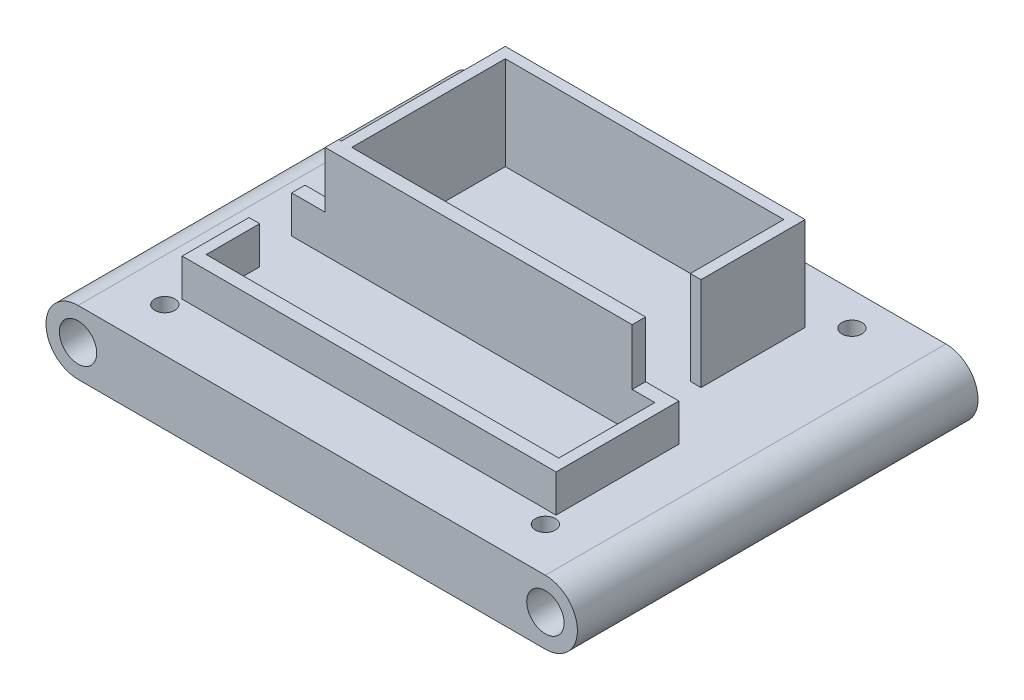
from build123d import *

# Parameters (mm, degrees)
SKETCH1_R           = 3.556
BOSS_EXTRUDE1_DEPTH = 76.2
SKETCH2_R           = 1.905
CUT_EXTRUDE1_DEPTH  = 6.604
BOSS_EXTRUDE2_DEPTH = 17.78
SKETCH4_W           = 6.858
SKETCH4_H           = 2.54
SKETCH4_W_2         = 2.54
SKETCH4_H_2         = 10.16
SKETCH4_H_3         = 18.288
BOSS_EXTRUDE3_DEPTH = 7.112
SKETCH5_R           = 1.905
CUT_EXTRUDE3_DEPTH  = 7.112
SKETCH6_R           = 1.905
CUT_EXTRUDE4_DEPTH  = 7.112
SKETCH8_W           = 0.508
SKETCH8_H           = 20.32
CUT_EXTRUDE5_DEPTH  = 17.78
SKETCH9_W           = 0.508
SKETCH9_H           = 2.54
CUT_EXTRUDE6_DEPTH  = 7.112
SKETCH10_W          = 0.508
SKETCH10_H          = 12.7
SKETCH10_H_2        = 23.368
CUT_EXTRUDE7_DEPTH  = 7.112
SKETCH11_W          = 57.041716114
SKETCH11_H          = 0.508
CUT_EXTRUDE8_DEPTH  = 17.78


with BuildPart() as part:
    # Sketch1 → Boss-Extrude1 (new body)
    with BuildSketch(Plane.XY):
        with BuildLine():
            Line((-44.45, 6.096), (44.45, 6.096))
            ThreePointArc((44.45, 6.096), (50.546, 0), (44.45, -6.096))
            Line((44.45, -6.096), (-44.45, -6.096))
            ThreePointArc((-44.45, -6.096), (-50.546, 0), (-44.45, 6.096))
        make_face()
        with Locations((-44.45, 0)):
            Circle(SKETCH1_R, mode=Mode.SUBTRACT)
        with Locations((44.45, 0)):
            Circle(SKETCH1_R, mode=Mode.SUBTRACT)
    extrude(amount=BOSS_EXTRUDE1_DEPTH)

    # Sketch2 → Cut-Extrude1 (cut)
    with BuildSketch(Plane.XZ.offset(6.096)):
        with Locations((-9.144, 69.215)):
            Circle(SKETCH2_R)
        with Locations((27.051, 60.833)):
            Circle(SKETCH2_R)
        with Locations((-28.956, 69.215)):
            Circle(SKETCH2_R)
        with Locations((-28.956, 6.985)):
            Circle(SKETCH2_R)
        with Locations((-9.144, 6.985)):
            Circle(SKETCH2_R)
        with Locations((11.049, 60.833)):
            Circle(SKETCH2_R)
        with Locations((11.049, 15.367)):
            Circle(SKETCH2_R)
        with Locations((27.051, 15.367)):
            Circle(SKETCH2_R)
    extrude(amount=-CUT_EXTRUDE1_DEPTH, mode=Mode.SUBTRACT)

    # Sketch3 → Boss-Extrude2 (add)
    with BuildSketch(Plane(origin=(0, 6.096, 0), x_dir=(1, 0, 0), z_dir=(0, 1, 0))):
        Polygon((-29.21, -10.16), (-29.21, -44.45), (29.21, -44.45), (29.21, -41.91), (-26.67, -41.91), (-26.67, -12.7), (26.307716114, -12.7), (26.307716114, -30.48), (28.847716114, -30.48), (28.847716114, -10.16), align=None)
    extrude(amount=BOSS_EXTRUDE2_DEPTH)

    # Sketch4 → Boss-Extrude3 (add)
    with BuildSketch(Plane(origin=(0, 6.096, 0), x_dir=(1, 0, 0), z_dir=(0, 1, 0))):
        with Locations((-32.639, -43.18)):
            Rectangle(SKETCH4_W, SKETCH4_H)
        with Locations((-34.798, -57.658)):
            Rectangle(SKETCH4_W_2, SKETCH4_H_2)
        Polygon((36.068, -62.738), (33.528, -62.738), (-33.528, -62.738), (-36.068, -62.738), (-36.068, -65.278), (36.068, -65.278), align=None)
        with Locations((34.798, -53.594)):
            Rectangle(SKETCH4_W_2, SKETCH4_H_3)
        with Locations((32.639, -43.18)):
            Rectangle(SKETCH4_W, SKETCH4_H)
    extrude(amount=BOSS_EXTRUDE3_DEPTH)

    # Sketch5 → Cut-Extrude3 (cut)
    with BuildSketch(Plane(origin=(0, 6.096, 0), x_dir=(1, 0, 0), z_dir=(0, 1, 0))):
        with Locations((36.068, -67.818)):
            Circle(SKETCH5_R)
        with Locations((32.911716114, -6.35)):
            Circle(SKETCH5_R)
    extrude(amount=-CUT_EXTRUDE3_DEPTH, mode=Mode.SUBTRACT)

    # Sketch6 → Cut-Extrude4 (cut)
    with BuildSketch(Plane(origin=(0, 6.096, 0), x_dir=(1, 0, 0), z_dir=(0, 1, 0))):
        with Locations((-33.274, -6.35)):
            Circle(SKETCH6_R)
        with Locations((-36.322, -67.818)):
            Circle(SKETCH6_R)
    extrude(amount=-CUT_EXTRUDE4_DEPTH, mode=Mode.SUBTRACT)

    # Sketch8 → Cut-Extrude5 (cut)
    with BuildSketch(Plane(origin=(0, 23.876, 0), x_dir=(1, 0, 0), z_dir=(0, 1, 0))):
        with Locations((28.593716114, -20.32)):
            Rectangle(SKETCH8_W, SKETCH8_H)
        Polygon((-28.702, -41.91), (-28.702, -10.16), (-29.21, -10.16), (-29.21, -41.825929555), align=None)
    extrude(amount=-CUT_EXTRUDE5_DEPTH, mode=Mode.SUBTRACT)

    # Sketch9 → Cut-Extrude6 (cut)
    with BuildSketch(Plane(origin=(0, 13.208, 0), x_dir=(1, 0, 0), z_dir=(0, 1, 0))):
        with Locations((-35.814, -43.18)):
            Rectangle(SKETCH9_W, SKETCH9_H)
    extrude(amount=-CUT_EXTRUDE6_DEPTH, mode=Mode.SUBTRACT)

    # Sketch10 → Cut-Extrude7 (cut)
    with BuildSketch(Plane(origin=(0, 13.208, 0), x_dir=(1, 0, 0), z_dir=(0, 1, 0))):
        with Locations((-35.814, -58.928)):
            Rectangle(SKETCH10_W, SKETCH10_H)
        with Locations((35.814, -53.594)):
            Rectangle(SKETCH10_W, SKETCH10_H_2)
    extrude(amount=-CUT_EXTRUDE7_DEPTH, mode=Mode.SUBTRACT)

    # Sketch11 → Cut-Extrude8 (cut)
    with BuildSketch(Plane(origin=(0, 23.876, 0), x_dir=(1, 0, 0), z_dir=(0, 1, 0))):
        with Locations((-0.181141943, -10.414)):
            Rectangle(SKETCH11_W, SKETCH11_H)
    extrude(amount=-CUT_EXTRUDE8_DEPTH, mode=Mode.SUBTRACT)


solid = part.part
